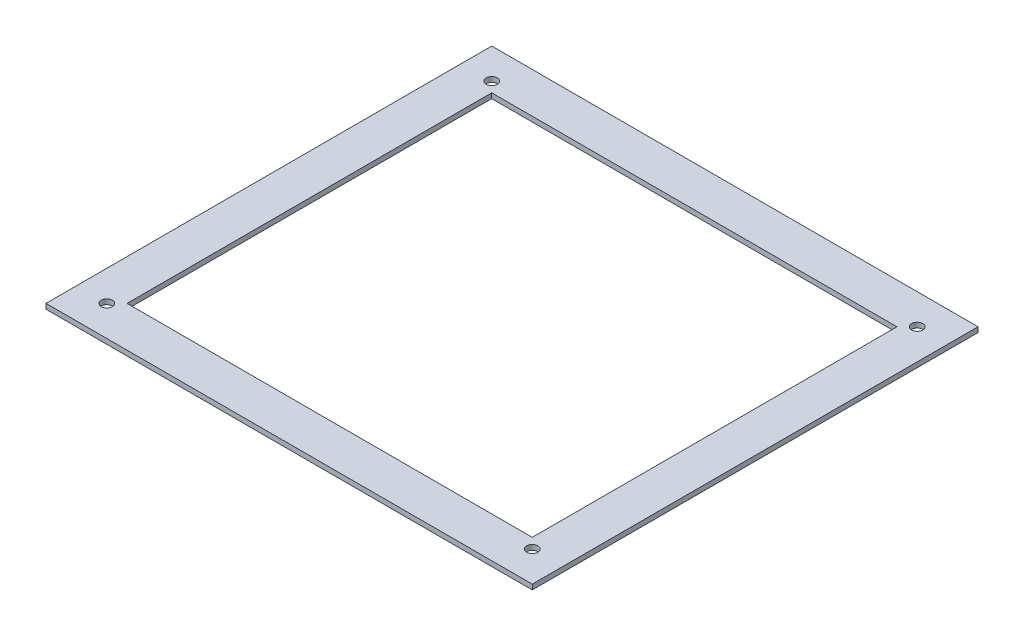
from build123d import *

# Parameters (mm, degrees)
SKETCH2_W           = 304.8
SKETCH2_H           = 279.4
SKETCH2_R           = 3.5
SKETCH2_W_2         = 254
SKETCH2_H_2         = 228.6
BOSS_EXTRUDE1_DEPTH = 3.175


with BuildPart() as part:
    # Sketch2 → Boss-Extrude1 (new body)
    with BuildSketch(Plane(origin=(0, 0, 0), x_dir=(1, 0, 0), z_dir=(0, 1, 0))):
        Rectangle(SKETCH2_W, SKETCH2_H)
        with Locations((-133.35, 120.65)):
            Circle(SKETCH2_R, mode=Mode.SUBTRACT)
        with Locations((133.35, 120.65)):
            Circle(SKETCH2_R, mode=Mode.SUBTRACT)
        with Locations((133.35, -120.65)):
            Circle(SKETCH2_R, mode=Mode.SUBTRACT)
        with Locations((-133.35, -120.65)):
            Circle(SKETCH2_R, mode=Mode.SUBTRACT)
        Rectangle(SKETCH2_W_2, SKETCH2_H_2, mode=Mode.SUBTRACT)
    extrude(amount=BOSS_EXTRUDE1_DEPTH)


solid = part.part
